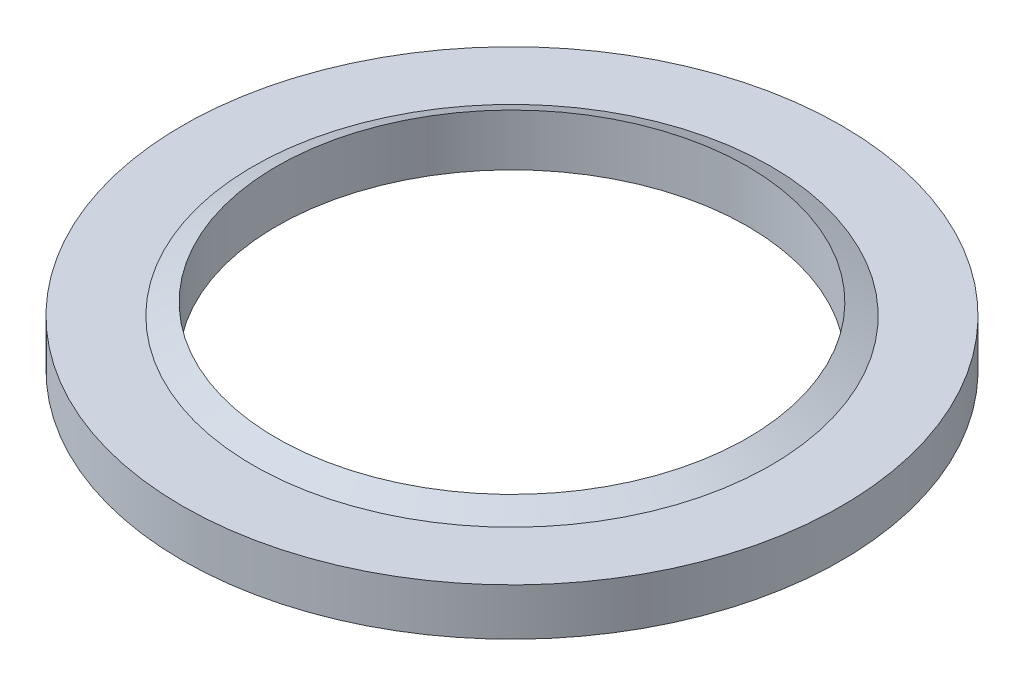
from build123d import *

# Parameters (mm, degrees)
SKETCH2_R          = 10.5
SKETCH2_R_2        = 10
CUT_EXTRUDE1_DEPTH = 0.3


with BuildPart() as part:
    # Sketch1 → Revolve1 (revolve)
    with BuildSketch(Plane.XY):
        Polygon((10, 0), (14, 0), (14, 2), (11, 2), (10, 2), align=None)
        Polygon((10, 2), (11, 2), (10, 2.5), align=None)
    revolve(axis=Axis((0, 0, 0), (0, 1, 0)))

    # Sketch2 → Cut-Extrude1 (cut)
    with BuildSketch(Plane.XZ):
        Circle(SKETCH2_R)
        Circle(SKETCH2_R_2, mode=Mode.SUBTRACT)
    extrude(amount=-CUT_EXTRUDE1_DEPTH, mode=Mode.SUBTRACT)


solid = part.part
